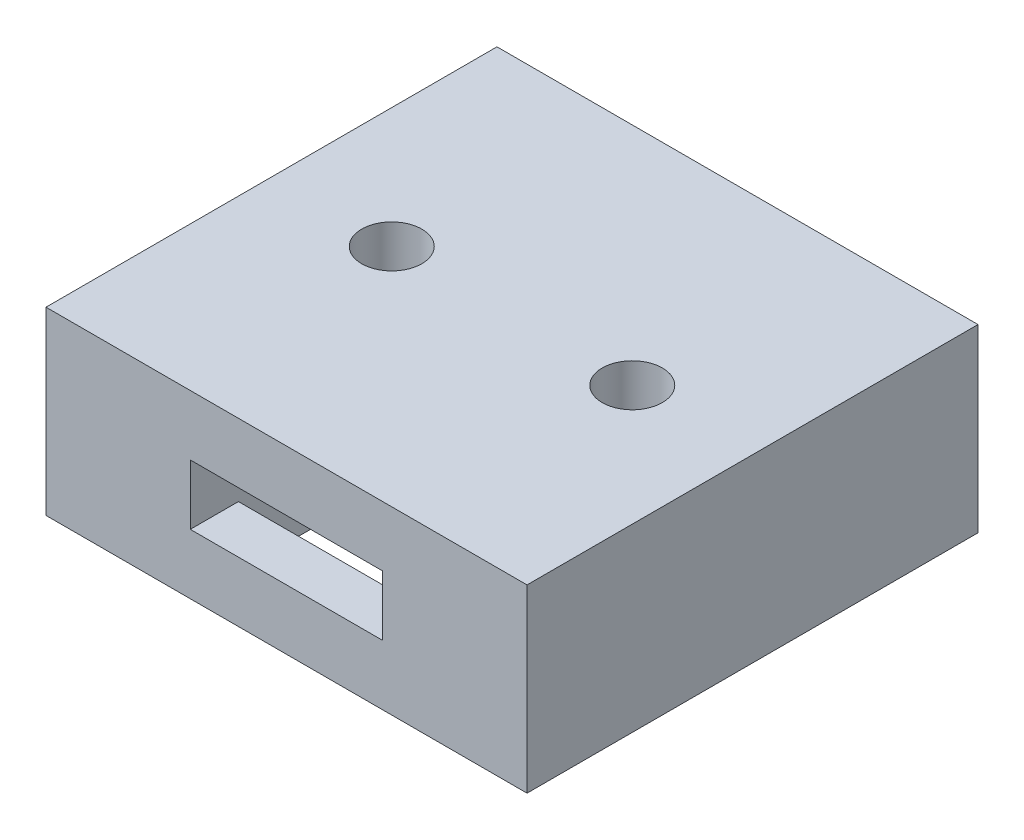
from build123d import *

# Parameters (mm, degrees)
CROQUIS1_W              = 16
CROQUIS1_H              = 15
CROQUIS1_R              = 1
SALIENTE_EXTRUIR1_DEPTH = 6
CROQUIS6_W              = 6.4
CROQUIS6_H              = 2
CORTAR_EXTRUIR3_DEPTH   = 32
CROQUIS7_W              = 6.4
CROQUIS7_H              = 2
CORTAR_EXTRUIR4_DEPTH   = 4.6
CROQUIS8_W              = 6.4
CROQUIS8_H              = 2
SALIENTE_EXTRUIR5_DEPTH = 2
CHAFL_N1_SIZE           = 1


with BuildPart() as part:
    # Croquis1 → Saliente-Extruir1 (new body)
    with BuildSketch(Plane(origin=(0, 0, 0), x_dir=(1, 0, 0), z_dir=(0, 1, 0))):
        Rectangle(CROQUIS1_W, CROQUIS1_H)
        with Locations((4, 0)):
            Circle(CROQUIS1_R, mode=Mode.SUBTRACT)
        with Locations((-4, 0)):
            Circle(CROQUIS1_R, mode=Mode.SUBTRACT)
    extrude(amount=SALIENTE_EXTRUIR1_DEPTH)

    # Croquis6 → Cortar-Extruir3 (cut)
    with BuildSketch(Plane(origin=(0, 6, 0), x_dir=(1, 0, 0), z_dir=(0, 1, 0))):
        with Locations((0, -3.9)):
            Rectangle(CROQUIS6_W, CROQUIS6_H)
        with Locations((0, 3.9)):
            Rectangle(CROQUIS6_W, CROQUIS6_H)
    cortar_extruir3 = extrude(amount=-CORTAR_EXTRUIR3_DEPTH, mode=Mode.SUBTRACT)

    # Croquis7 → Cortar-Extruir4 (cut)
    with BuildSketch(Plane(origin=(0, 0, 7.5), x_dir=(-1, 0, 0), z_dir=(0, 0, -1))):
        with Locations((0, 3)):
            Rectangle(CROQUIS7_W, CROQUIS7_H)
    cortar_extruir4 = extrude(amount=CORTAR_EXTRUIR4_DEPTH, mode=Mode.SUBTRACT)

    # Simetría1: Cortar-Extruir3, Cortar-Extruir4 across plane
    add(cortar_extruir3.mirror(Plane.XY), mode=Mode.SUBTRACT)
    add(cortar_extruir4.mirror(Plane.XY), mode=Mode.SUBTRACT)

    # Croquis8 → Saliente-Extruir5 (add)
    with BuildSketch(Plane(origin=(0, 6, 0), x_dir=(1, 0, 0), z_dir=(0, 1, 0))):
        with Locations((0, 3.9)):
            Rectangle(CROQUIS8_W, CROQUIS8_H)
        with Locations((0, -3.9)):
            Rectangle(CROQUIS8_W, CROQUIS8_H)
    extrude(amount=-SALIENTE_EXTRUIR5_DEPTH)

    # Chaflán1
    chafl_n1_edges = [part.edges().sort_by_distance(p)[0] for p in [
        (0, 2, -4.9),
        (0, 2, 4.9),
    ]]
    chamfer(chafl_n1_edges, length=CHAFL_N1_SIZE)


solid = part.part
